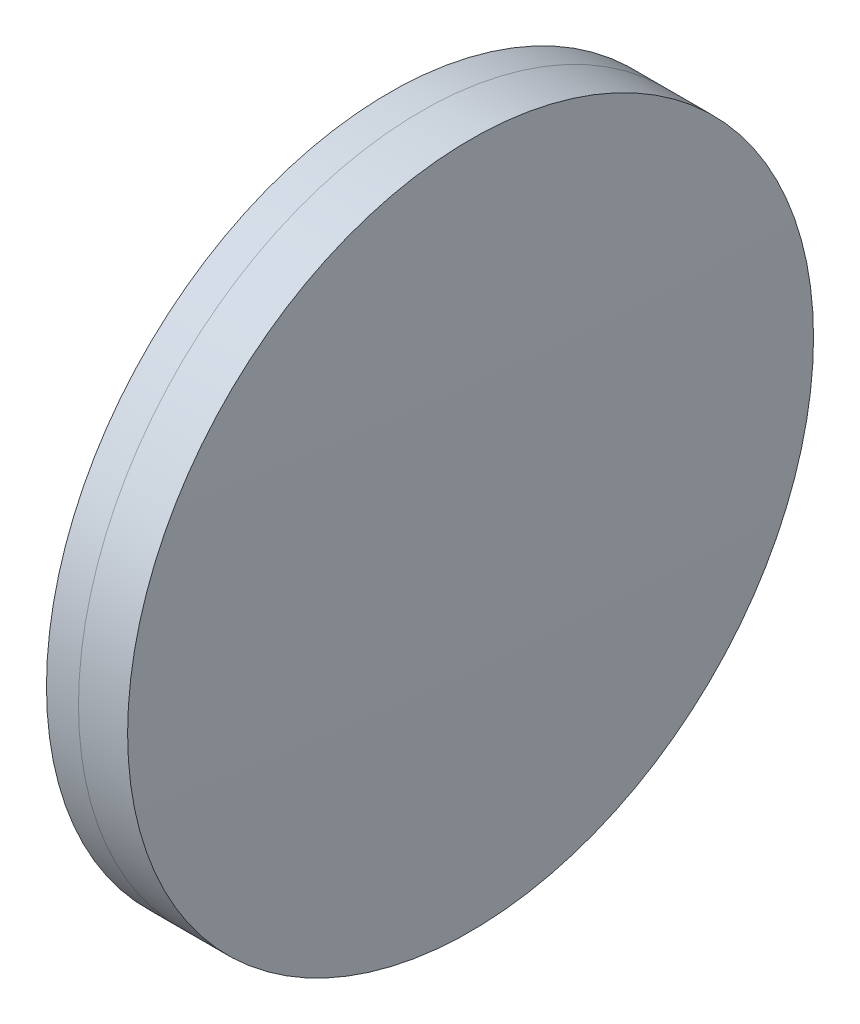
from build123d import *


with BuildPart() as part:
    # 草图1 one side → 旋转1 (revolve)
    with BuildSketch(Plane(origin=(0, 0, 0), x_dir=(1, 0, 0), z_dir=(0, 1, 0)), mode=Mode.PRIVATE) as revolve_1_sk:
        with BuildLine():
            ThreePointArc((310.506638112, 20), (309.895057668, 10.008310641), (309.691084604, 0))
            Line((309.691084604, 0), (313.611084604, 0))
            ThreePointArc((313.611084604, 0), (313.301716488, 10.019087061), (312.374790876, 20))
            Line((312.374790876, 20), (310.506638112, 20))
        make_face()
    revolve(revolve_1_sk.sketch.rotate(Axis((124.523309526, 0, 0), (1, 0, 0)), 180), axis=Axis((124.523309526, 0, 0), (1, 0, 0)))  # turned: the seam where the file's is


with BuildPart() as body_2:
    # 草图2 one side → 旋转3 (revolve)
    with BuildSketch(Plane(origin=(0, 0, 0), x_dir=(1, 0, 0), z_dir=(0, 1, 0)), mode=Mode.PRIVATE) as revolve_3_sk:
        with BuildLine():
            Line((315.237692038, 20), (312.374790876, 20))
            ThreePointArc((312.374790876, 20), (313.301716488, 10.019087061), (313.611084604, 0))
            Line((313.611084604, 0), (315.611084604, 0))
            ThreePointArc((315.611084604, 0), (315.51772833, 10.001742623), (315.237692038, 20))
        make_face()
    revolve(revolve_3_sk.sketch.rotate(Axis((-0.551919993, 0, 0), (1, 0, 0)), 180), axis=Axis((-0.551919993, 0, 0), (1, 0, 0)))  # turned: the seam where the file's is


solid = Compound([part.part, body_2.part])
